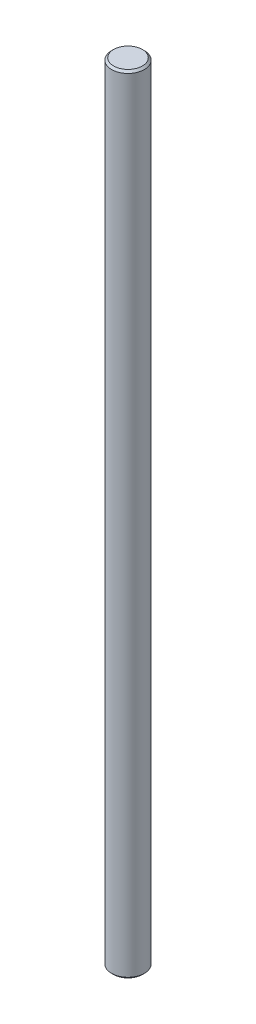
from build123d import *

# Parameters (mm, degrees)
SKETCH1_R           = 4
BOSS_EXTRUDE1_DEPTH = 192
CHAMFER1_SIZE       = 0.5


with BuildPart() as part:
    # Sketch1 → Boss-Extrude1 (new body)
    with BuildSketch(Plane(origin=(0, 0, 0), x_dir=(1, 0, 0), z_dir=(0, 1, 0))):
        Circle(SKETCH1_R)
    extrude(amount=BOSS_EXTRUDE1_DEPTH)

    # Chamfer1
    chamfer1_edges = [part.edges().sort_by_distance(p)[0] for p in [
        (-4, 0, 0),
        (-4, 192, 0),
    ]]
    chamfer(chamfer1_edges, length=CHAMFER1_SIZE)


solid = part.part
